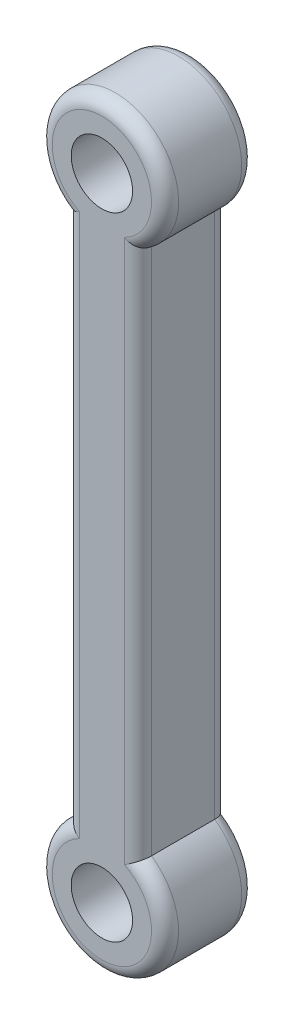
from build123d import *

# Parameters (mm, degrees)
CROQUIS1_R              = 1.7
SALIENTE_EXTRUIR1_DEPTH = 5
REDONDEO1_R             = 0.75


with BuildPart() as part:
    # Croquis1 → Saliente-Extruir1 (new body)
    with BuildSketch(Plane.XY):
        with BuildLine():
            Line((2, -14.627718677), (2, 14.627718677))
            ThreePointArc((2, 14.627718677), (0, 21), (-2, 14.627718677))
            Line((-2, 14.627718677), (-2, -14.627718677))
            ThreePointArc((-2, -14.627718677), (0, -21), (2, -14.627718677))
        make_face()
        with Locations((0, -17.5)):
            Circle(CROQUIS1_R, mode=Mode.SUBTRACT)
        with Locations((0, 17.5)):
            Circle(CROQUIS1_R, mode=Mode.SUBTRACT)
    extrude(amount=SALIENTE_EXTRUIR1_DEPTH)

    # Redondeo1
    redondeo1_edges = [part.edges().sort_by_distance(p)[0] for p in [
        (0, -21, 5),
        (2, 0, 5),
        (0, 21, 5),
        (2, 0, 0),
        (0, -21, 0),
        (-2, 0, 0),
        (0, 21, 0),
        (-2, 0, 5),
    ]]
    fillet(redondeo1_edges, radius=REDONDEO1_R)


solid = part.part
